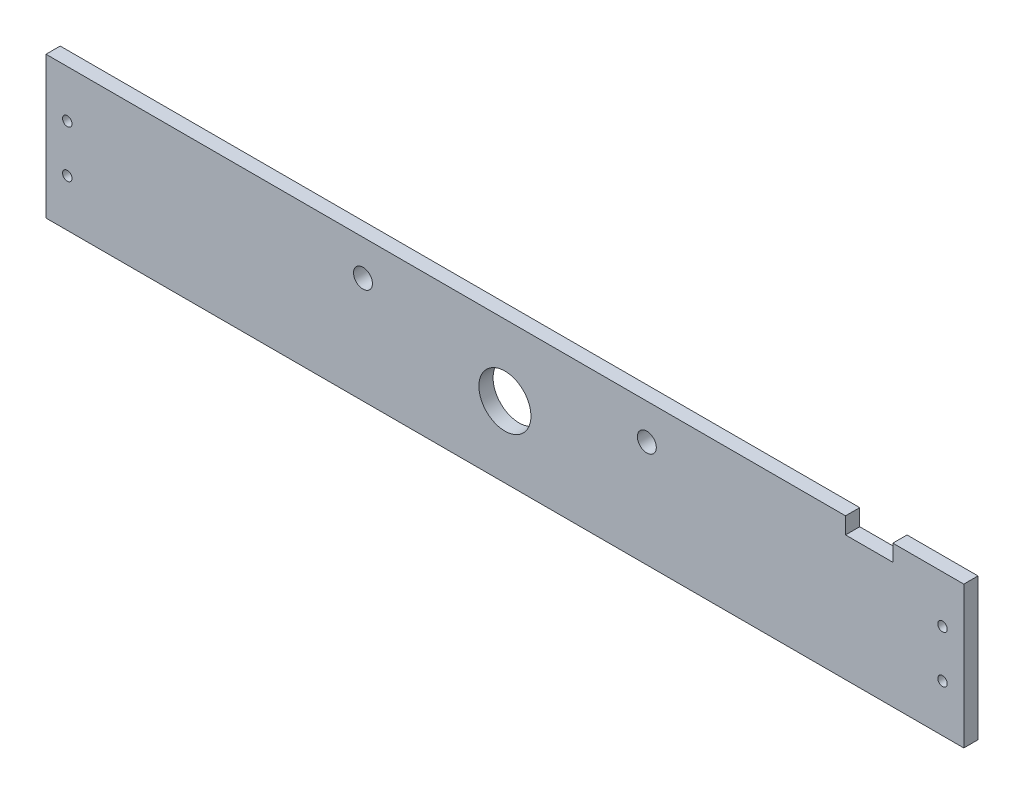
from build123d import *

# Parameters (mm, degrees)
SKETCH1_R           = 2
SKETCH1_R_2         = 4
SKETCH1_R_3         = 11
BOSS_EXTRUDE1_DEPTH = 6


with BuildPart() as part:
    # Sketch1 → Boss-Extrude1 (new body)
    with BuildSketch(Plane.XY):
        Polygon((-194, 30), (-194, -30), (194, -30), (194, 30), (164, 30), (164, 23), (144, 23), (144, 30), align=None)
        with Locations((-185, -10)):
            Circle(SKETCH1_R, mode=Mode.SUBTRACT)
        with Locations((185, -10)):
            Circle(SKETCH1_R, mode=Mode.SUBTRACT)
        with Locations((-185, 10)):
            Circle(SKETCH1_R, mode=Mode.SUBTRACT)
        with Locations((-60, 15)):
            Circle(SKETCH1_R_2, mode=Mode.SUBTRACT)
        Circle(SKETCH1_R_3, mode=Mode.SUBTRACT)
        with Locations((185, 10)):
            Circle(SKETCH1_R, mode=Mode.SUBTRACT)
        with Locations((60, 15)):
            Circle(SKETCH1_R_2, mode=Mode.SUBTRACT)
    extrude(amount=BOSS_EXTRUDE1_DEPTH)


solid = part.part
